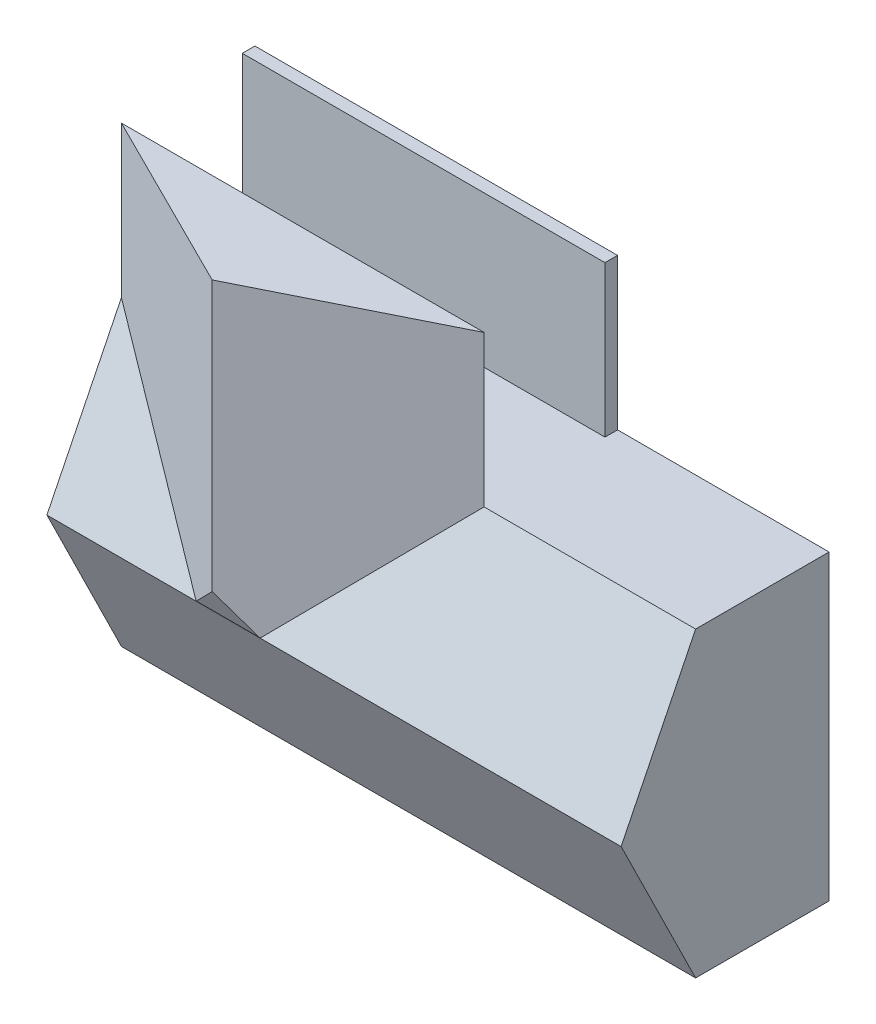
from build123d import *

# Parameters (mm, degrees)
SKETCH3_W           = 11582.4
SKETCH3_H           = 6096
SKETCH3_W_2         = 4341.154286856
SKETCH3_H_2         = 914.4
SKETCH3_W_3         = 1676.4
SKETCH3_H_3         = 2330.801356814
SKETCH3_W_4         = 2663.595025017
SKETCH3_H_4         = 2342.798643186
SKETCH3_W_5         = 1043.645713144
SKETCH3_W_6         = 4013.2
SKETCH3_W_7         = 3708.4
BOSS_EXTRUDE1_DEPTH = 2438.4
SKETCH4_W           = 11582.4
SKETCH4_H           = 6096
BOSS_EXTRUDE2_DEPTH = 254
SKETCH5_W           = 3178.404974983
SKETCH5_H           = 101.6
BOSS_EXTRUDE3_DEPTH = 1016
BOSS_EXTRUDE4_DEPTH = 11582.4
SKETCH8_W           = 7315.2
SKETCH8_H           = 3048
BOSS_EXTRUDE6_DEPTH = 254
BOSS_EXTRUDE7_DEPTH = 6085.84
SKETCH11_W          = 3360.991367567
SKETCH11_H          = 1045.401535637
CUT_EXTRUDE1_DEPTH  = 6085.84


with BuildPart() as part:
    # Sketch3 → Boss-Extrude1 (new body)
    with BuildSketch(Plane.XY):
        with Locations((5791.2, 3048)):
            Rectangle(SKETCH3_W, SKETCH3_H)
        Polygon((152.4, 152.4), (4550.004974983, 152.4), (4550.004974983, 2596.798643186), (5842, 2596.798643186), (5842, 3511.198643186), (5842, 5943.6), (152.4, 5943.6), align=None, mode=Mode.SUBTRACT)
        with Locations((8114.177143428, 3053.998643186)):
            Rectangle(SKETCH3_W_2, SKETCH3_H_2, mode=Mode.SUBTRACT)
        with Locations((6781.8, 4778.199321593)):
            Rectangle(SKETCH3_W_3, SKETCH3_H_3, mode=Mode.SUBTRACT)
        with Locations((5983.402487492, 1323.799321593)):
            Rectangle(SKETCH3_W_4, SKETCH3_H_4, mode=Mode.SUBTRACT)
        with Locations((10908.177143428, 3053.998643186)):
            Rectangle(SKETCH3_W_5, SKETCH3_H_2, mode=Mode.SUBTRACT)
        with Locations((9423.4, 1323.799321593)):
            Rectangle(SKETCH3_W_6, SKETCH3_H_4, mode=Mode.SUBTRACT)
        with Locations((9575.8, 4778.199321593)):
            Rectangle(SKETCH3_W_7, SKETCH3_H_3, mode=Mode.SUBTRACT)
    extrude(amount=BOSS_EXTRUDE1_DEPTH)

    # Sketch4 → Boss-Extrude2 (add)
    with BuildSketch(Plane(origin=(0, 0, 0), x_dir=(-1, 0, 0), z_dir=(0, 0, -1))):
        with Locations((-5791.2, 3048)):
            Rectangle(SKETCH4_W, SKETCH4_H)
    extrude(amount=BOSS_EXTRUDE2_DEPTH)

    # Sketch5 → Boss-Extrude3 (add)
    with BuildSketch(Plane.XY):
        with Locations((1741.602487492, 2545.998643186)):
            Rectangle(SKETCH5_W, SKETCH5_H)
    extrude(amount=BOSS_EXTRUDE3_DEPTH)

    # Sketch6 → Boss-Extrude4 (add)
    with BuildSketch(Plane.ZY):
        Polygon((2438.4, 6096), (2438.4, 0), (3941.507258543, 3048), align=None)
    extrude(amount=-BOSS_EXTRUDE4_DEPTH)

    # Sketch10 → Boss-Extrude7 (add)
    with BuildSketch(Plane(origin=(0, 9144, 0), x_dir=(1, 0, 0), z_dir=(0, 1, 0))):
        Polygon((7315.2, -2438.4), (0, -2438.4), (3655.110432816, -4263.253342026), align=None)
    extrude(amount=-BOSS_EXTRUDE7_DEPTH)

    # Sketch11 → Cut-Extrude1 (cut)
    with BuildSketch(Plane(origin=(0, -967.256392483, 1961.401934247), x_dir=(1, 0, 0), z_dir=(0, -0.44228869, 0.896872742))):
        with Locations((3764.422731341, 4778.811583623)):
            Rectangle(SKETCH11_W, SKETCH11_H)
    extrude(amount=CUT_EXTRUDE1_DEPTH, mode=Mode.SUBTRACT)


with BuildPart() as body_2:
    # Sketch8 → Boss-Extrude6 (new body)
    with BuildSketch(Plane(origin=(0, 0, -254), x_dir=(-1, 0, 0), z_dir=(0, 0, -1))):
        with Locations((-3657.6, 7620)):
            Rectangle(SKETCH8_W, SKETCH8_H)
    extrude(amount=-BOSS_EXTRUDE6_DEPTH)


solid = Compound([part.part, body_2.part])
